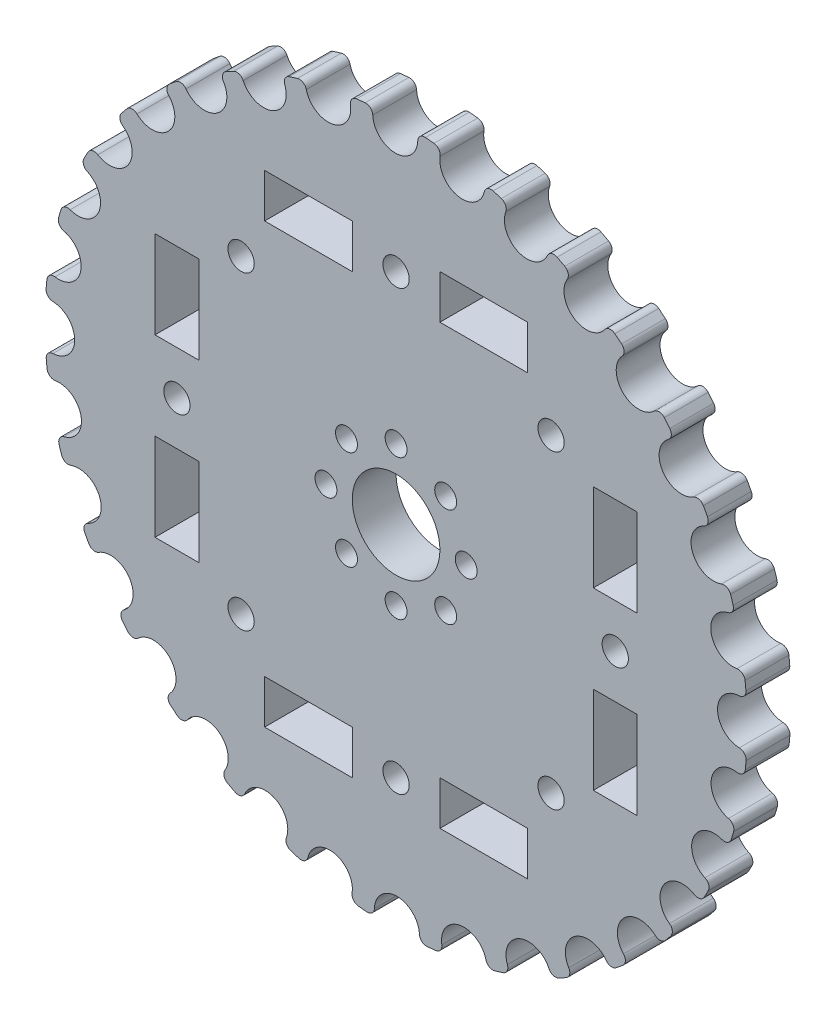
from build123d import *

# Parameters (mm, degrees)
SCHIZZO1_R                   = 40.062660939
ESTRUSIONE_ESTRUSIONE1_DEPTH = 5
SCHIZZO2_R                   = 2.57
TAGLIO_ESTRUSIONE1_DEPTH     = 6
RACCORDO1_R                  = 0.8
SCHIZZO3_R                   = 5
TAGLIO_ESTRUSIONE2_DEPTH     = 6.0000001
SCHIZZO4_R                   = 1.25
SCHIZZO4_R_2                 = 1.5
SCHIZZO4_W                   = 5
SCHIZZO4_H                   = 10
SCHIZZO4_W_2                 = 10
SCHIZZO4_H_2                 = 5
TAGLIO_ESTRUSIONE3_DEPTH     = 6.0000001


with BuildPart() as part:
    # Schizzo1 → Estrusione-Estrusione1 (new body)
    with BuildSketch(Plane.XY):
        Circle(SCHIZZO1_R)
    extrude(amount=ESTRUSIONE_ESTRUSIONE1_DEPTH)

    # Schizzo2 → Taglio-Estrusione1 (cut, through all)
    with BuildSketch(Plane.XY):
        with Locations((-0.093519434, 39.234888545)):
            Circle(SCHIZZO2_R)
        with Locations((7.562660721, 38.499613085)):
            Circle(SCHIZZO2_R)
        with Locations((14.928284395, 36.284819086)):
            Circle(SCHIZZO2_R)
        with Locations((21.7202948, 32.675619837)):
            Circle(SCHIZZO2_R)
        with Locations((27.677678787, 27.810714843)):
            Circle(SCHIZZO2_R)
        with Locations((32.571497429, 21.877059674)):
            Circle(SCHIZZO2_R)
        with Locations((36.21368402, 15.102681371)):
            Circle(SCHIZZO2_R)
        with Locations((38.464271373, 7.747915492)):
            Circle(SCHIZZO2_R)
        with Locations((39.236770677, 0.095401566)):
            Circle(SCHIZZO2_R)
        with Locations((38.501495217, -7.560778589)):
            Circle(SCHIZZO2_R)
        with Locations((36.286701218, -14.926402263)):
            Circle(SCHIZZO2_R)
        with Locations((32.677501969, -21.718412668)):
            Circle(SCHIZZO2_R)
        with Locations((27.812596975, -27.675796655)):
            Circle(SCHIZZO2_R)
        with Locations((21.878941807, -32.569615297)):
            Circle(SCHIZZO2_R)
        with Locations((15.104563503, -36.211801888)):
            Circle(SCHIZZO2_R)
        with Locations((7.749797624, -38.462389241)):
            Circle(SCHIZZO2_R)
        with Locations((0.097283698, -39.234888545)):
            Circle(SCHIZZO2_R)
        with Locations((-7.558896457, -38.499613085)):
            Circle(SCHIZZO2_R)
        with Locations((-14.92452013, -36.284819086)):
            Circle(SCHIZZO2_R)
        with Locations((-21.716530536, -32.675619837)):
            Circle(SCHIZZO2_R)
        with Locations((-27.673914523, -27.810714843)):
            Circle(SCHIZZO2_R)
        with Locations((-32.567733165, -21.877059674)):
            Circle(SCHIZZO2_R)
        with Locations((-36.209919756, -15.102681371)):
            Circle(SCHIZZO2_R)
        with Locations((-38.460507109, -7.747915492)):
            Circle(SCHIZZO2_R)
        with Locations((-39.233006413, -0.095401566)):
            Circle(SCHIZZO2_R)
        with Locations((-38.497730953, 7.560778589)):
            Circle(SCHIZZO2_R)
        with Locations((-36.282936953, 14.926402263)):
            Circle(SCHIZZO2_R)
        with Locations((-32.673737705, 21.718412668)):
            Circle(SCHIZZO2_R)
        with Locations((-27.808832711, 27.675796655)):
            Circle(SCHIZZO2_R)
        with Locations((-21.875177542, 32.569615297)):
            Circle(SCHIZZO2_R)
        with Locations((-15.100799239, 36.211801888)):
            Circle(SCHIZZO2_R)
        with Locations((-7.74603336, 38.462389241)):
            Circle(SCHIZZO2_R)
    extrude(amount=TAGLIO_ESTRUSIONE1_DEPTH, mode=Mode.SUBTRACT)

    # Raccordo1
    raccordo1_edges = [part.edges().sort_by_distance(p)[0] for p in [
        (31.942109789, -24.180951671, 2.5),
        (34.663171869, -20.086844389, 2.5),
        (26.611153993, -29.94767578, 2.5),
        (30.078524478, -26.463166227, 2.5),
        (20.257609847, -34.563652076, 2.5),
        (24.337986317, -31.822621255, 2.5),
        (13.125595942, -37.851493137, 2.5),
        (17.662122402, -35.959230161, 2.5),
        (5.489149667, -39.684833847, 2.5),
        (10.307451953, -38.713992764, 2.5),
        (-2.358297523, -39.993189849, 2.5),
        (2.556595149, -39.981003273, 2.5),
        (-10.115191512, -38.764670799, 2.5),
        (-5.292585413, -39.711526553, 2.5),
        (-17.483441203, -36.046443447, 2.5),
        (-12.938431635, -37.915877787, 2.5),
        (10.11906027, 38.763661086, 2.5),
        (-24.179873687, -31.942925821, 2.5),
        (-20.087085287, -34.663032271, 2.5),
        (5.296099227, 39.711058088, 2.5),
        (-29.947118726, -26.611780879, 2.5),
        (-26.46378579, -30.077979373, 2.5),
        (-34.563503922, -20.257862625, 2.5),
        (-31.823435482, -24.336921654, 2.5),
        (-37.85157961, -13.125346568, 2.5),
        (-35.960025392, -17.660503258, 2.5),
        (-39.684944931, -5.488346503, 2.5),
        (-38.714558233, -10.305327861, 2.5),
        (-39.993111736, 2.359621835, 2.5),
        (-39.981163224, -2.554092556, 2.5),
        (-38.764218427, 10.11692499, 2.5),
        (-39.711167015, 5.295282413, 2.5),
        (-36.045488681, 17.485409554, 2.5),
        (-37.914963935, 12.941109354, 2.5),
        (-31.941416979, 24.181866819, 2.5),
        (-34.661613715, 20.089533001, 2.5),
        (-26.609750631, 29.948922733, 2.5),
        (-30.076182583, 26.46582783, 2.5),
        (17.487042146, 36.044696676, 2.5),
        (-20.255423044, 34.564933659, 2.5),
        (-24.334930677, 31.824957981, 2.5),
        (12.941372162, 37.914874232, 2.5),
        (-13.122672082, 37.852506904, 2.5),
        (-17.658531673, 35.9609936, 2.5),
        (-5.485647344, 39.685318126, 2.5),
        (-10.303586252, 38.715021785, 2.5),
        (24.182945141, 31.940600586, 2.5),
        (20.089291397, 34.661753745, 2.5),
        (29.949479628, 26.60912384, 2.5),
        (26.465208159, 30.076727857, 2.5),
        (34.565081384, 20.255170956, 2.5),
        (31.824144106, 24.335995015, 2.5),
        (37.852420015, 13.122922714, 2.5),
        (35.960198926, 17.660149906, 2.5),
        (39.685206872, 5.486452137, 2.5),
        (38.714456796, 10.305708927, 2.5),
        (39.993041872, -2.360805648, 2.5),
        (39.981088796, 2.555257362, 2.5),
        (2.36213165, 39.992963576, 2.5),
        (38.764113933, -10.117325363, 2.5),
        (39.711417465, -5.293403861, 2.5),
        (-2.552756457, 39.981248554, 2.5),
        (36.045652002, -17.48507287, 2.5),
        (37.915787671, -12.938695713, 2.5),
    ]]
    fillet(raccordo1_edges, radius=RACCORDO1_R)

    # Schizzo3 → Taglio-Estrusione2 (cut, through all)
    with BuildSketch(Plane.XY):
        Circle(SCHIZZO3_R)
    extrude(amount=TAGLIO_ESTRUSIONE2_DEPTH, mode=Mode.SUBTRACT)

    # Schizzo4 → Taglio-Estrusione3 (cut, through all)
    with BuildSketch(Plane.XY):
        with Locations((0, 8)):
            Circle(SCHIZZO4_R)
        with Locations((5.656854249, 5.656854249)):
            Circle(SCHIZZO4_R)
        with Locations((8, 0)):
            Circle(SCHIZZO4_R)
        with Locations((5.656854249, -5.656854249)):
            Circle(SCHIZZO4_R)
        with Locations((0, -8)):
            Circle(SCHIZZO4_R)
        with Locations((-5.656854249, -5.656854249)):
            Circle(SCHIZZO4_R)
        with Locations((-8, 0)):
            Circle(SCHIZZO4_R)
        with Locations((-5.656854249, 5.656854249)):
            Circle(SCHIZZO4_R)
        with Locations((0, 25)):
            Circle(SCHIZZO4_R_2)
        with Locations((17.67766953, 17.67766953)):
            Circle(SCHIZZO4_R_2)
        with Locations((25, 0)):
            Circle(SCHIZZO4_R_2)
        with Locations((17.67766953, -17.67766953)):
            Circle(SCHIZZO4_R_2)
        with Locations((0, -25)):
            Circle(SCHIZZO4_R_2)
        with Locations((-17.67766953, -17.67766953)):
            Circle(SCHIZZO4_R_2)
        with Locations((-25, 0)):
            Circle(SCHIZZO4_R_2)
        with Locations((-17.67766953, 17.67766953)):
            Circle(SCHIZZO4_R_2)
        with Locations((-25, 10)):
            Rectangle(SCHIZZO4_W, SCHIZZO4_H)
        with Locations((-25, -10)):
            Rectangle(SCHIZZO4_W, SCHIZZO4_H)
        with Locations((10, 25)):
            Rectangle(SCHIZZO4_W_2, SCHIZZO4_H_2)
        with Locations((-10, 25)):
            Rectangle(SCHIZZO4_W_2, SCHIZZO4_H_2)
        with Locations((25, -10)):
            Rectangle(SCHIZZO4_W, SCHIZZO4_H)
        with Locations((25, 10)):
            Rectangle(SCHIZZO4_W, SCHIZZO4_H)
        with Locations((-10, -25)):
            Rectangle(SCHIZZO4_W_2, SCHIZZO4_H_2)
        with Locations((10, -25)):
            Rectangle(SCHIZZO4_W_2, SCHIZZO4_H_2)
    extrude(amount=TAGLIO_ESTRUSIONE3_DEPTH, mode=Mode.SUBTRACT)


solid = part.part
